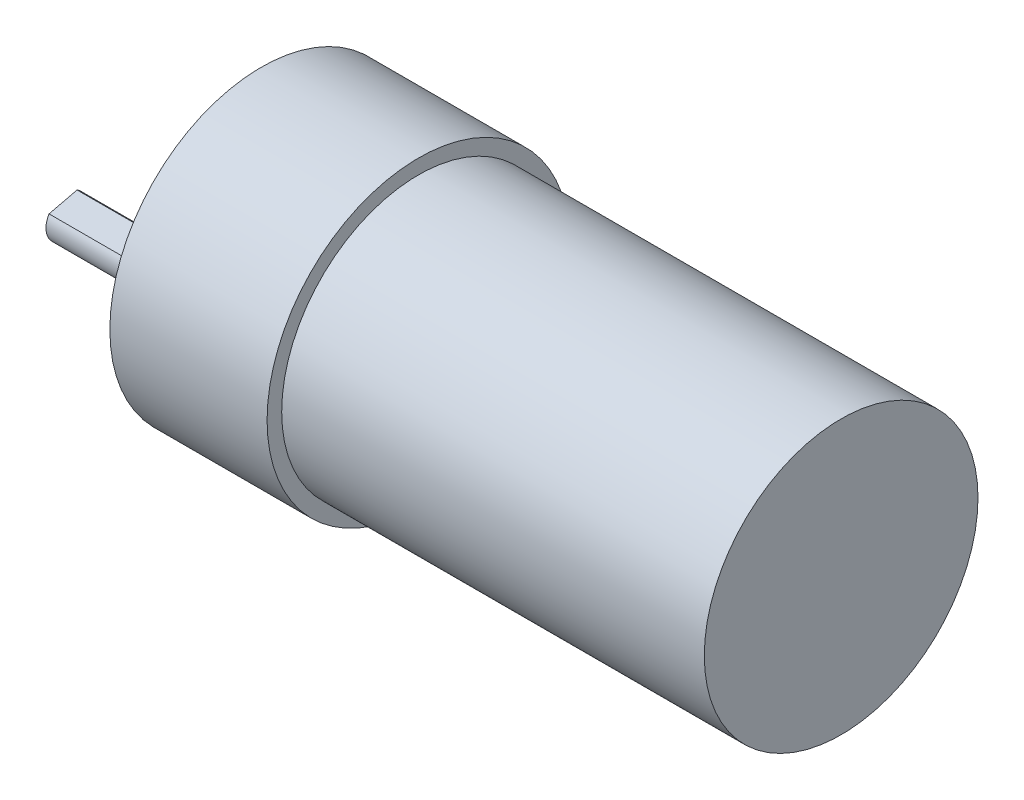
from build123d import *

# Parameters (mm, degrees)
SKETCH1_R          = 15.875
EXTRUDE1_DEPTH     = 49.022
SKETCH3_R          = 17.56918
EXTRUDE3_DEPTH     = 18.2372
SKETCH4_R          = 2.3749
EXTRUDE4_DEPTH     = 22.606
SKETCH5_R          = 1.27
CUT_EXTRUDE1_DEPTH = 10
SKETCH6_R          = 1.27
CUT_EXTRUDE2_DEPTH = 10
SKETCH7_W          = 17.727088037
SKETCH7_H          = 11.013879898
CUT_EXTRUDE3_DEPTH = 0.6858


with BuildPart() as part:
    # Sketch1 → Extrude1 (new body)
    with BuildSketch(Plane(origin=(0, 0, 0), x_dir=(0, 0, -1), z_dir=(1, 0, 0))):
        Circle(SKETCH1_R)
    extrude(amount=EXTRUDE1_DEPTH)

    # Sketch3 → Extrude3 (add)
    with BuildSketch(Plane.ZY):
        Circle(SKETCH3_R)
    extrude(amount=EXTRUDE3_DEPTH)

    # Sketch4 → Extrude4 (add)
    with BuildSketch(Plane.ZY.offset(18.2372)):
        with Locations((0, -8.71855)):
            Circle(SKETCH4_R)
    extrude(amount=EXTRUDE4_DEPTH)

    # Sketch5 → Cut-Extrude1 (cut)
    with BuildSketch(Plane.ZY.offset(18.2372)):
        with Locations((0, 13.45565)):
            Circle(SKETCH5_R)
    extrude(amount=-CUT_EXTRUDE1_DEPTH, mode=Mode.SUBTRACT)

    # Sketch6 → Cut-Extrude2 (cut)
    with BuildSketch(Plane.ZY.offset(18.2372)):
        with Locations((10.2108, -8.71855)):
            Circle(SKETCH6_R)
        with Locations((-10.2108, -8.71855)):
            Circle(SKETCH6_R)
    extrude(amount=-CUT_EXTRUDE2_DEPTH, mode=Mode.SUBTRACT)

    # Sketch7 → Cut-Extrude3 (cut)
    with BuildSketch(Plane(origin=(0, -5.937135101, -1.41983909), x_dir=(-1, 0, 0), z_dir=(0, 0.972575579, 0.232587065))):
        with Locations((34.720744018, 1.438658771)):
            Rectangle(SKETCH7_W, SKETCH7_H)
    extrude(amount=-CUT_EXTRUDE3_DEPTH, mode=Mode.SUBTRACT)


solid = part.part
